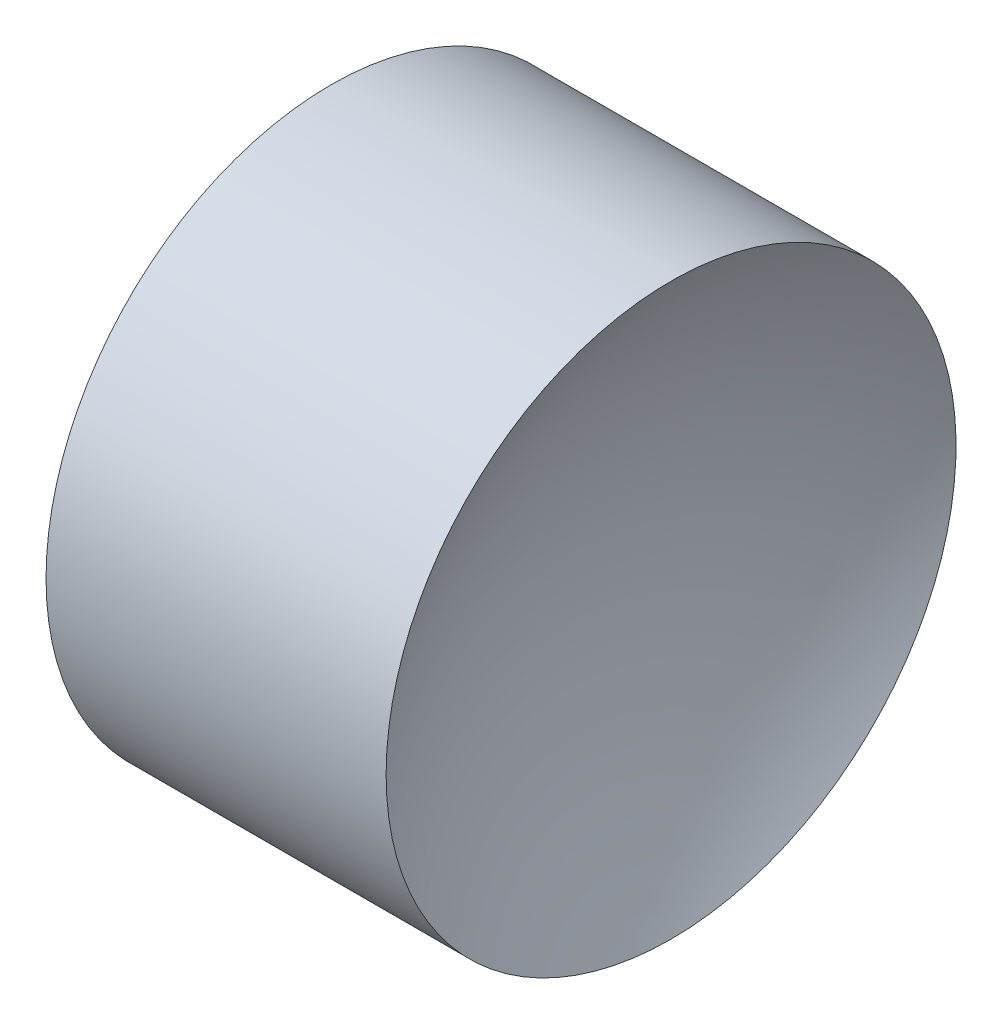
from build123d import *


with BuildPart() as part:
    # 草图2 → 旋转1 (revolve)
    with BuildSketch(Plane.XY, mode=Mode.PRIVATE) as revolve_1_sk:
        with BuildLine():
            Line((23.011852872, 13.044520575), (25.011852872, 13.044520575))
            ThreePointArc((25.011852872, 13.044520575), (25.235886687, 14.679775919), (25.891477885, 16.194520575))
            Line((25.891477885, 16.194520575), (24.011852872, 16.194520575))
            Line((24.011852872, 16.194520575), (22.132227858, 16.194520575))
            ThreePointArc((22.132227858, 16.194520575), (22.787819057, 14.679775919), (23.011852872, 13.044520575))
        make_face()
    revolve(revolve_1_sk.sketch.rotate(Axis((21.224930557, 13.044520575, 0), (1, 0, 0)), 90), axis=Axis((21.224930557, 13.044520575, 0), (1, 0, 0)))  # turned: the seam where the file's is


solid = part.part
